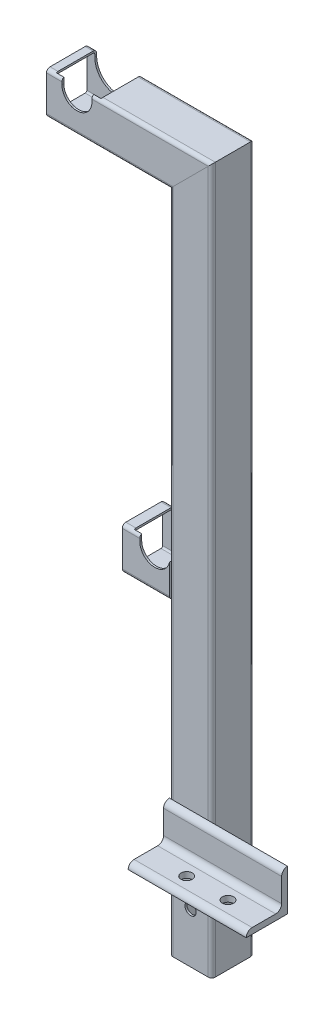
from build123d import *

# Parameters (mm, degrees)
STRUCTURAL_MEMBERMAIN_DEPTH                   = 1
STRUCTURAL_MEMBERMAIN_DEPTH_BACK              = 80
STRUCTURAL_MEMBERMAIN_2_DEPTH                 = 527.314422766
STRUCTURAL_MEMBERMAIN_3_DEPTH                 = 148.414422766
STRUCTURAL_MEMBERMAIN_4_DEPTH                 = 58.9
CUT_EXTRUDETOPRAILGUIDE_DEPTH                 = 635.563414015
CUT_EXTRUDETOPRAILGUIDE_DEPTH_BACK            = 635.563414015
STRUCTURAL_MEMBERANGLE_DEPTH                  = 100
SKETCH15_R                                    = 4.7625
CUT_EXTRUDEMOUNTINGHOLES_DEPTH                = 676.49630747
CUT_EXTRUDEENLARGERAILGUIDE_DEPTH             = 676.49630747
CUT_EXTRUDEENLARGERAILGUIDE_DIRECTION_2_REACH = 677.496
CUT_EXTRUDE2_DEPTH                            = 675.372665079
SKETCH19_R                                    = 4.7625
CUT_EXTRUDE3_DEPTH                            = 675.372665085
CUT_EXTRUDE4_START                            = -34.2
CUT_EXTRUDE4_DEPTH                            = 34.2


with BuildPart() as part:
    # Sketch11 → Structural MemberMain (new, two sides)
    with BuildSketch(Plane(origin=(348.3375, 0, 0), x_dir=(-1, 0, 0), z_dir=(0, 1, 0))) as structural_membermain_sk:
        with BuildLine():
            Line((-14.9, 17.9), (14.9, 17.9))
            ThreePointArc((14.9, 17.9), (17.021320344, 17.021320344), (17.9, 14.9))
            Line((17.9, 14.9), (17.9, -14.9))
            ThreePointArc((17.9, -14.9), (17.021320344, -17.021320344), (14.9, -17.9))
            Line((14.9, -17.9), (-14.9, -17.9))
            ThreePointArc((-14.9, -17.9), (-17.021320344, -17.021320344), (-17.9, -14.9))
            Line((-17.9, -14.9), (-17.9, 14.9))
            ThreePointArc((-17.9, 14.9), (-17.021320344, 17.021320344), (-14.9, 17.9))
        make_face()
        with BuildLine():
            Line((-14.9, 16.3), (14.9, 16.3))
            ThreePointArc((14.9, 16.3), (15.889949494, 15.889949494), (16.3, 14.9))
            Line((16.3, 14.9), (16.3, -14.9))
            ThreePointArc((16.3, -14.9), (15.889949494, -15.889949494), (14.9, -16.3))
            Line((14.9, -16.3), (-14.9, -16.3))
            ThreePointArc((-14.9, -16.3), (-15.889949494, -15.889949494), (-16.3, -14.9))
            Line((-16.3, -14.9), (-16.3, 14.9))
            ThreePointArc((-16.3, 14.9), (-15.889949494, 15.889949494), (-14.9, 16.3))
        make_face(mode=Mode.SUBTRACT)
    extrude(amount=STRUCTURAL_MEMBERMAIN_DEPTH)
    extrude(structural_membermain_sk.sketch, amount=-STRUCTURAL_MEMBERMAIN_DEPTH_BACK)

    # Structural MemberMain mitre 1
    split(bisect_by=Plane(origin=(348.3375, 0, 0), x_dir=(1, 0, 0), z_dir=(0, -1, 0)), keep=Keep.TOP)

    # Sketch19 → Cut-Extrude3 (cut, through all)
    with BuildSketch(Plane.XY.offset(17.9)):
        with Locations((348.3375, -37.5)):
            Circle(SKETCH19_R)
    extrude(amount=-CUT_EXTRUDE3_DEPTH, mode=Mode.SUBTRACT)


with BuildPart() as body_2:
    # Sketch11 on segment 2 (carried to segment 2) → Structural MemberMain 2 (new body)
    with BuildSketch(Plane(origin=(348.3375, -1, 0), x_dir=(-1, 0, 0), z_dir=(0, 1, 0))):
        with BuildLine():
            Line((-14.9, 17.9), (14.9, 17.9))
            ThreePointArc((14.9, 17.9), (17.021320344, 17.021320344), (17.9, 14.9))
            Line((17.9, 14.9), (17.9, -14.9))
            ThreePointArc((17.9, -14.9), (17.021320344, -17.021320344), (14.9, -17.9))
            Line((14.9, -17.9), (-14.9, -17.9))
            ThreePointArc((-14.9, -17.9), (-17.021320344, -17.021320344), (-17.9, -14.9))
            Line((-17.9, -14.9), (-17.9, 14.9))
            ThreePointArc((-17.9, 14.9), (-17.021320344, 17.021320344), (-14.9, 17.9))
        make_face()
        with BuildLine():
            Line((-14.9, 16.3), (14.9, 16.3))
            ThreePointArc((14.9, 16.3), (15.889949494, 15.889949494), (16.3, 14.9))
            Line((16.3, 14.9), (16.3, -14.9))
            ThreePointArc((16.3, -14.9), (15.889949494, -15.889949494), (14.9, -16.3))
            Line((14.9, -16.3), (-14.9, -16.3))
            ThreePointArc((-14.9, -16.3), (-15.889949494, -15.889949494), (-16.3, -14.9))
            Line((-16.3, -14.9), (-16.3, 14.9))
            ThreePointArc((-16.3, 14.9), (-15.889949494, 15.889949494), (-14.9, 16.3))
        make_face(mode=Mode.SUBTRACT)
    extrude(amount=STRUCTURAL_MEMBERMAIN_2_DEPTH)

    # Structural MemberMain 2 mitre 1
    split(bisect_by=Plane(origin=(348.3375, 0, 0), x_dir=(-1, 0, 0), z_dir=(0, 1, 0)), keep=Keep.TOP)

    # Structural MemberMain 2 mitre 2
    split(bisect_by=Plane(origin=(348.3375, 500, 0), x_dir=(0.707106781, 0.707106781, 0), z_dir=(0.707106781, -0.707106781, 0)), keep=Keep.TOP)


with BuildPart() as body_3:
    # Sketch11 on segment 3 (carried to segment 3) → Structural MemberMain 3 (new body)
    with BuildSketch(Plane(origin=(374.651922766, 500, 0), x_dir=(0, -1, 0), z_dir=(-1, 0, 0))):
        with BuildLine():
            Line((-14.9, 17.9), (14.9, 17.9))
            ThreePointArc((14.9, 17.9), (17.021320344, 17.021320344), (17.9, 14.9))
            Line((17.9, 14.9), (17.9, -14.9))
            ThreePointArc((17.9, -14.9), (17.021320344, -17.021320344), (14.9, -17.9))
            Line((14.9, -17.9), (-14.9, -17.9))
            ThreePointArc((-14.9, -17.9), (-17.021320344, -17.021320344), (-17.9, -14.9))
            Line((-17.9, -14.9), (-17.9, 14.9))
            ThreePointArc((-17.9, 14.9), (-17.021320344, 17.021320344), (-14.9, 17.9))
        make_face()
        with BuildLine():
            Line((-14.9, 16.3), (14.9, 16.3))
            ThreePointArc((14.9, 16.3), (15.889949494, 15.889949494), (16.3, 14.9))
            Line((16.3, 14.9), (16.3, -14.9))
            ThreePointArc((16.3, -14.9), (15.889949494, -15.889949494), (14.9, -16.3))
            Line((14.9, -16.3), (-14.9, -16.3))
            ThreePointArc((-14.9, -16.3), (-15.889949494, -15.889949494), (-16.3, -14.9))
            Line((-16.3, -14.9), (-16.3, 14.9))
            ThreePointArc((-16.3, 14.9), (-15.889949494, 15.889949494), (-14.9, 16.3))
        make_face(mode=Mode.SUBTRACT)
    extrude(amount=STRUCTURAL_MEMBERMAIN_3_DEPTH)

    # Structural MemberMain 3 mitre 1
    split(bisect_by=Plane(origin=(348.3375, 500, 0), x_dir=(-0.707106781, -0.707106781, 0), z_dir=(-0.707106781, 0.707106781, 0)), keep=Keep.TOP)

    # Sketch12 → Cut-ExtrudeTopRailGuide (cut, two sides)
    with BuildSketch(Plane.XY) as cut_extrudetoprailguide_sk:
        with BuildLine():
            Line((239.3, 512.7), (239.3, 523.1))
            ThreePointArc((239.3, 523.1), (252, 535.8), (264.7, 523.1))
            Line((264.7, 523.1), (264.7, 512.7))
            ThreePointArc((264.7, 512.7), (252, 500), (239.3, 512.7))
        make_face()
    extrude(amount=CUT_EXTRUDETOPRAILGUIDE_DEPTH, mode=Mode.SUBTRACT)
    extrude(cut_extrudetoprailguide_sk.sketch, amount=-CUT_EXTRUDETOPRAILGUIDE_DEPTH_BACK, mode=Mode.SUBTRACT)

    # Sketch16 → Cut-ExtrudeEnlargeRailGuide (cut)
    with BuildSketch(Plane.XY):
        with BuildLine():
            Line((271.05, 512.7), (271.05, 523.1))
            ThreePointArc((271.05, 523.1), (252, 542.15), (232.95, 523.1))
            Line((232.95, 523.1), (232.95, 512.7))
            ThreePointArc((232.95, 512.7), (252, 493.65), (271.05, 512.7))
        make_face()
    extrude(amount=-CUT_EXTRUDEENLARGERAILGUIDE_DEPTH, mode=Mode.SUBTRACT)

    # Cut-ExtrudeEnlargeRailGuide direction 2: up to this face of the body (flat: up to its plane)
    cut_extrudeenlargerailguide_direction_2_end = Plane(body_3.part.faces().sort_by_distance((290.896237065, 499.874495333, 16.3))[0])
    # Sketch16 → Cut-ExtrudeEnlargeRailGuide direction 2 (cut, up to the picked face)
    with BuildSketch(Plane.XY, mode=Mode.PRIVATE) as cut_extrudeenlargerailguide_direction_2_sk1:
        with BuildLine():
            Line((271.05, 512.7), (271.05, 523.1))
            ThreePointArc((271.05, 523.1), (252, 542.15), (232.95, 523.1))
            Line((232.95, 523.1), (232.95, 512.7))
            ThreePointArc((232.95, 512.7), (252, 493.65), (271.05, 512.7))
        make_face()
    cut_extrudeenlargerailguide_direction_2_tool1 = split(extrude(cut_extrudeenlargerailguide_direction_2_sk1.sketch, amount=CUT_EXTRUDEENLARGERAILGUIDE_DIRECTION_2_REACH, mode=Mode.PRIVATE), bisect_by=cut_extrudeenlargerailguide_direction_2_end, keep=Keep.BOTH, mode=Mode.PRIVATE)
    add(cut_extrudeenlargerailguide_direction_2_tool1.solids().sort_by(Axis((252, 517.9, 0), (0, 0, 1)))[0], mode=Mode.SUBTRACT)


with BuildPart() as body_4:
    # Sketch11 on segment 4 (carried to segment 4) → Structural MemberMain 4 (new body)
    with BuildSketch(Plane(origin=(290.4375, 198, 0), x_dir=(0, 1, 0), z_dir=(1, 0, 0))):
        with BuildLine():
            Line((-14.9, 17.9), (14.9, 17.9))
            ThreePointArc((14.9, 17.9), (17.021320344, 17.021320344), (17.9, 14.9))
            Line((17.9, 14.9), (17.9, -14.9))
            ThreePointArc((17.9, -14.9), (17.021320344, -17.021320344), (14.9, -17.9))
            Line((14.9, -17.9), (-14.9, -17.9))
            ThreePointArc((-14.9, -17.9), (-17.021320344, -17.021320344), (-17.9, -14.9))
            Line((-17.9, -14.9), (-17.9, 14.9))
            ThreePointArc((-17.9, 14.9), (-17.021320344, 17.021320344), (-14.9, 17.9))
        make_face()
        with BuildLine():
            Line((-14.9, 16.3), (14.9, 16.3))
            ThreePointArc((14.9, 16.3), (15.889949494, 15.889949494), (16.3, 14.9))
            Line((16.3, 14.9), (16.3, -14.9))
            ThreePointArc((16.3, -14.9), (15.889949494, -15.889949494), (14.9, -16.3))
            Line((14.9, -16.3), (-14.9, -16.3))
            ThreePointArc((-14.9, -16.3), (-15.889949494, -15.889949494), (-16.3, -14.9))
            Line((-16.3, -14.9), (-16.3, 14.9))
            ThreePointArc((-16.3, 14.9), (-15.889949494, 15.889949494), (-14.9, 16.3))
        make_face(mode=Mode.SUBTRACT)
    extrude(amount=STRUCTURAL_MEMBERMAIN_4_DEPTH)

    # Structural MemberMain 4 mitre 1
    split(bisect_by=Plane(origin=(330.4375, 198, 0), x_dir=(0, -1, 0), z_dir=(-1, 0, 0)), keep=Keep.TOP)


with BuildPart() as body_5:
    # Sketch14 → Structural MemberAngle (new body)
    with BuildSketch(Plane(origin=(330.4375, 0, 17.9), x_dir=(0, 1, 0), z_dir=(1, 0, 0))):
        with BuildLine():
            Line((0, 0), (0, 35))
            ThreePointArc((0, 35), (3.535533906, 33.535533906), (5, 30))
            Line((5, 30), (5, 10))
            ThreePointArc((5, 10), (6.464466094, 6.464466094), (10, 5))
            Line((10, 5), (30, 5))
            ThreePointArc((30, 5), (33.535533906, 3.535533906), (35, 0))
            Line((35, 0), (0, 0))
        make_face()
    extrude(amount=STRUCTURAL_MEMBERANGLE_DEPTH)

    # Sketch15 → Cut-ExtrudeMountingHoles (cut, through all)
    with BuildSketch(Plane(origin=(0, 0, 0), x_dir=(1, 0, 0), z_dir=(0, 1, 0))):
        with Locations(Location((365, -37.9, 0), (0, 0, 90))):
            Circle(SKETCH15_R)
        with Locations(Location((400, -37.9, 0), (0, 0, 90))):
            Circle(SKETCH15_R)
    extrude(amount=CUT_EXTRUDEMOUNTINGHOLES_DEPTH, mode=Mode.SUBTRACT)


with BuildPart() as cut_extrude2_tool:
    # Sketch18 → Cut-Extrude2 (new, through all)
    with BuildSketch(Plane.XY.offset(17.9)):
        with BuildLine():
            Line((305.3, 210.7), (305.3, 221.1))
            ThreePointArc((305.3, 221.1), (318, 233.8), (330.7, 221.1))
            Line((330.7, 221.1), (330.7, 210.7))
            ThreePointArc((330.7, 210.7), (318, 198), (305.3, 210.7))
        make_face()
    extrude(amount=-CUT_EXTRUDE2_DEPTH)


with BuildPart() as body_2_1:
    add(body_2.part)

    # Cut-Extrude2: cut by cut_extrude2_tool
    add(cut_extrude2_tool.part, mode=Mode.SUBTRACT)


with BuildPart() as body_4_1:
    add(body_4.part)

    # Cut-Extrude2: cut by cut_extrude2_tool
    add(cut_extrude2_tool.part, mode=Mode.SUBTRACT)


with BuildPart() as cut_extrude4_tool:
    # Sketch20 → Cut-Extrude4 (new body)
    with BuildSketch(Plane(origin=(0, 0, -17.9), x_dir=(-1, 0, 0), z_dir=(0, 0, -1)).offset(CUT_EXTRUDE4_START)):
        with BuildLine():
            Line((-337.05, 221.1), (-337.05, 210.7))
            ThreePointArc((-337.05, 210.7), (-318, 191.65), (-298.95, 210.7))
            Line((-298.95, 210.7), (-298.95, 221.1))
            ThreePointArc((-298.95, 221.1), (-318, 240.15), (-337.05, 221.1))
        make_face()
    extrude(amount=CUT_EXTRUDE4_DEPTH)


with BuildPart() as body_2_2:
    add(body_2_1.part)

    # Cut-Extrude4: cut by cut_extrude4_tool
    add(cut_extrude4_tool.part, mode=Mode.SUBTRACT)


with BuildPart() as body_4_2:
    add(body_4_1.part)

    # Cut-Extrude4: cut by cut_extrude4_tool
    add(cut_extrude4_tool.part, mode=Mode.SUBTRACT)


solid = Compound([part.part, body_3.part, body_5.part, body_2_2.part, body_4_2.part])
